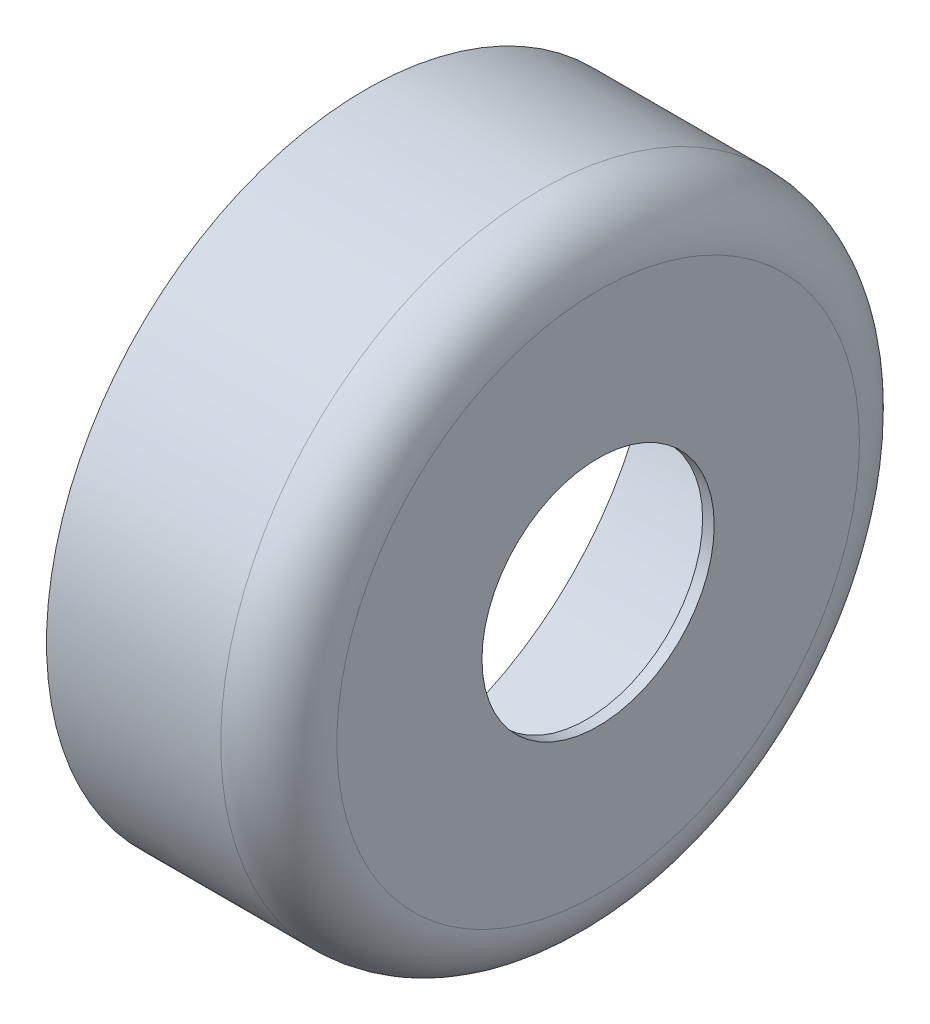
from build123d import *

# Parameters (mm, degrees)
SKETCH1_R           = 55
BOSS_EXTRUDE1_DEPTH = 40
SKETCH2_R           = 50
CUT_EXTRUDE1_DEPTH  = 38
SKETCH3_R           = 20
CUT_EXTRUDE2_DEPTH  = 38
FILLET1_R           = 10


with BuildPart() as part:
    # Sketch1 → Boss-Extrude1 (new body)
    with BuildSketch(Plane(origin=(0, 0, 0), x_dir=(0, 0, -1), z_dir=(1, 0, 0))):
        Circle(SKETCH1_R)
    extrude(amount=BOSS_EXTRUDE1_DEPTH)

    # Sketch2 → Cut-Extrude1 (cut)
    with BuildSketch(Plane.ZY):
        Circle(SKETCH2_R)
    extrude(amount=-CUT_EXTRUDE1_DEPTH, mode=Mode.SUBTRACT)

    # Sketch3 → Cut-Extrude2 (cut)
    with BuildSketch(Plane(origin=(40, 0, 0), x_dir=(0, 0, -1), z_dir=(1, 0, 0))):
        Circle(SKETCH3_R)
    extrude(amount=-CUT_EXTRUDE2_DEPTH, mode=Mode.SUBTRACT)

    # Fillet1
    fillet1_edges = [part.edges().sort_by_distance(p)[0] for p in [
        (40, 0, 55),
    ]]
    fillet(fillet1_edges, radius=FILLET1_R)


solid = part.part
